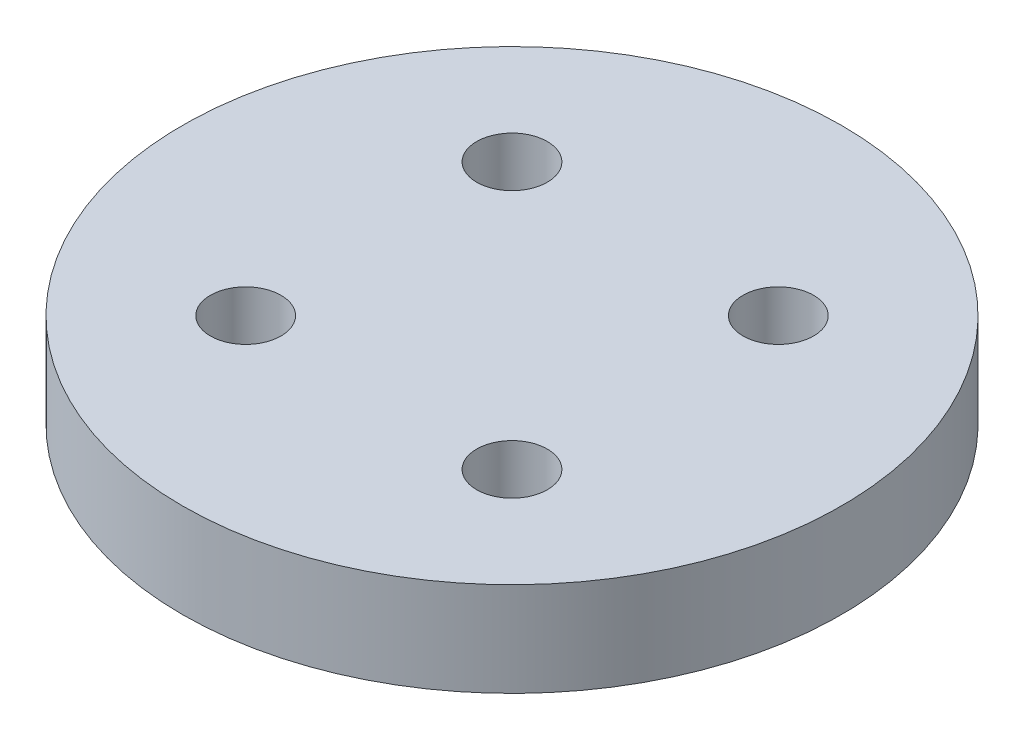
from build123d import *

# Parameters (mm, degrees)
SKETCH_1_R      = 14
SKETCH_1_R_2    = 1.5
EXTRUDE_1_DEPTH = 4


with BuildPart() as part:
    # 草图1 → 凸台-拉伸1 (new body)
    with BuildSketch(Plane(origin=(0, 0, 0), x_dir=(1, 0, 0), z_dir=(0, 1, 0))):
        Circle(SKETCH_1_R)
        with Locations((-5.656854249, 5.656854249)):
            Circle(SKETCH_1_R_2, mode=Mode.SUBTRACT)
        with Locations((5.656854249, 5.656854249)):
            Circle(SKETCH_1_R_2, mode=Mode.SUBTRACT)
        with Locations((5.656854249, -5.656854249)):
            Circle(SKETCH_1_R_2, mode=Mode.SUBTRACT)
        with Locations((-5.656854249, -5.656854249)):
            Circle(SKETCH_1_R_2, mode=Mode.SUBTRACT)
    extrude(amount=EXTRUDE_1_DEPTH)


solid = part.part
